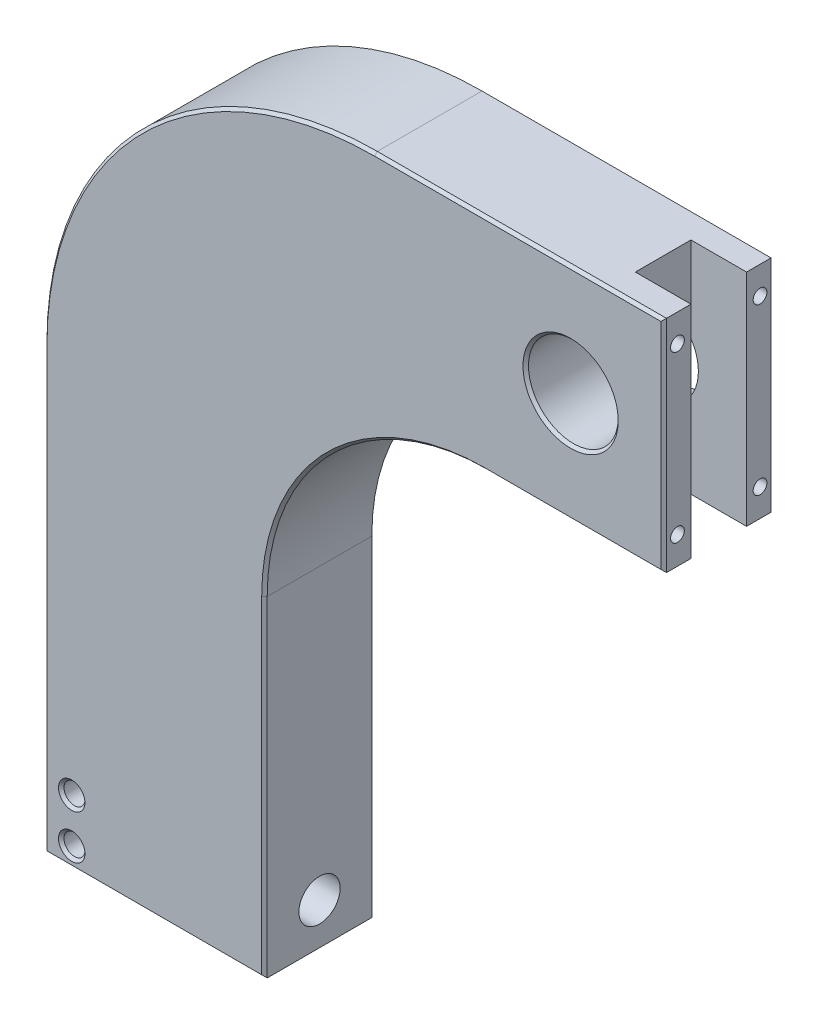
from build123d import *

# Parameters (mm, degrees)
SKETCH1_R           = 0.19
SKETCH1_R_2         = 0.815
BOSS_EXTRUDE1_DEPTH = 1
SKETCH2_R           = 0.375
CUT_EXTRUDE1_DEPTH  = 0.75
SKETCH3_W           = 1.01
SKETCH3_H           = 1.01
CUT_EXTRUDE2_DEPTH  = 15
SKETCH4_R           = 0.125
CUT_EXTRUDE3_DEPTH  = 1.01
CHAMFER1_SIZE       = 0.05


with BuildPart() as part:
    # Sketch1 → Boss-Extrude1 (new body, symmetric)
    with BuildSketch(Plane.XY):
        with BuildLine():
            Line((0, 0), (0, 8))
            ThreePointArc((0, 8), (1.757359313, 12.242640687), (6, 14))
            Line((6, 14), (11.25, 14))
            Line((11.25, 14), (11.25, 10))
            Line((11.25, 10), (8, 10))
            ThreePointArc((8, 10), (5.171572875, 8.828427125), (4, 6))
            Line((4, 6), (4, 0))
            Line((4, 0), (0, 0))
        make_face()
        with Locations((0.5, 0.35)):
            Circle(SKETCH1_R, mode=Mode.SUBTRACT)
        with Locations((0.5, 1.15)):
            Circle(SKETCH1_R, mode=Mode.SUBTRACT)
        with Locations((9.56, 12)):
            Circle(SKETCH1_R_2, mode=Mode.SUBTRACT)
    extrude(amount=BOSS_EXTRUDE1_DEPTH, both=True)

    # Sketch2 → Cut-Extrude1 (cut)
    with BuildSketch(Plane(origin=(4, 0, 0), x_dir=(0, 0, -1), z_dir=(1, 0, 0))):
        with Locations((0, 0.75)):
            Circle(SKETCH2_R)
    extrude(amount=-CUT_EXTRUDE1_DEPTH, mode=Mode.SUBTRACT)

    # Sketch3 → Cut-Extrude2 (cut, through all)
    with BuildSketch(Plane(origin=(0, 14, 0), x_dir=(1, 0, 0), z_dir=(0, 1, 0))):
        with Locations((10.745, 0)):
            Rectangle(SKETCH3_W, SKETCH3_H)
    extrude(amount=-CUT_EXTRUDE2_DEPTH, mode=Mode.SUBTRACT)

    # Sketch4 → Cut-Extrude3 (cut)
    with BuildSketch(Plane(origin=(11.25, 0, 0), x_dir=(0, 0, -1), z_dir=(1, 0, 0))):
        with Locations((0.75, 13.5)):
            Circle(SKETCH4_R)
        with Locations((0.75, 10.5)):
            Circle(SKETCH4_R)
        with Locations((-0.75, 10.5)):
            Circle(SKETCH4_R)
        with Locations((-0.75, 13.5)):
            Circle(SKETCH4_R)
    extrude(amount=-CUT_EXTRUDE3_DEPTH, mode=Mode.SUBTRACT)

    # Chamfer1
    chamfer1_edges = [part.edges().sort_by_distance(p)[0] for p in [
        (9.625, 10, -1),
        (5.171572875, 8.828427125, -1),
        (4, 3, -1),
        (2, 0, -1),
        (5.171572875, 8.828427125, 1),
        (9.625, 10, 1),
        (11.25, 12, 1),
        (0.31, 0.35, -1),
        (0.31, 0.35, 1),
        (8.625, 14, 1),
        (0.31, 1.15, -1),
        (0.31, 1.15, 1),
        (1.757359313, 12.242640687, 1),
        (8.745, 12, -1),
        (8.745, 12, 1),
        (0, 4, 1),
        (2, 0, 1),
        (0, 4, -1),
        (4, 3, 1),
        (1.757359313, 12.242640687, -1),
        (8.625, 14, -1),
        (11.25, 12, -1),
    ]]
    chamfer(chamfer1_edges, length=CHAMFER1_SIZE)


solid = part.part
